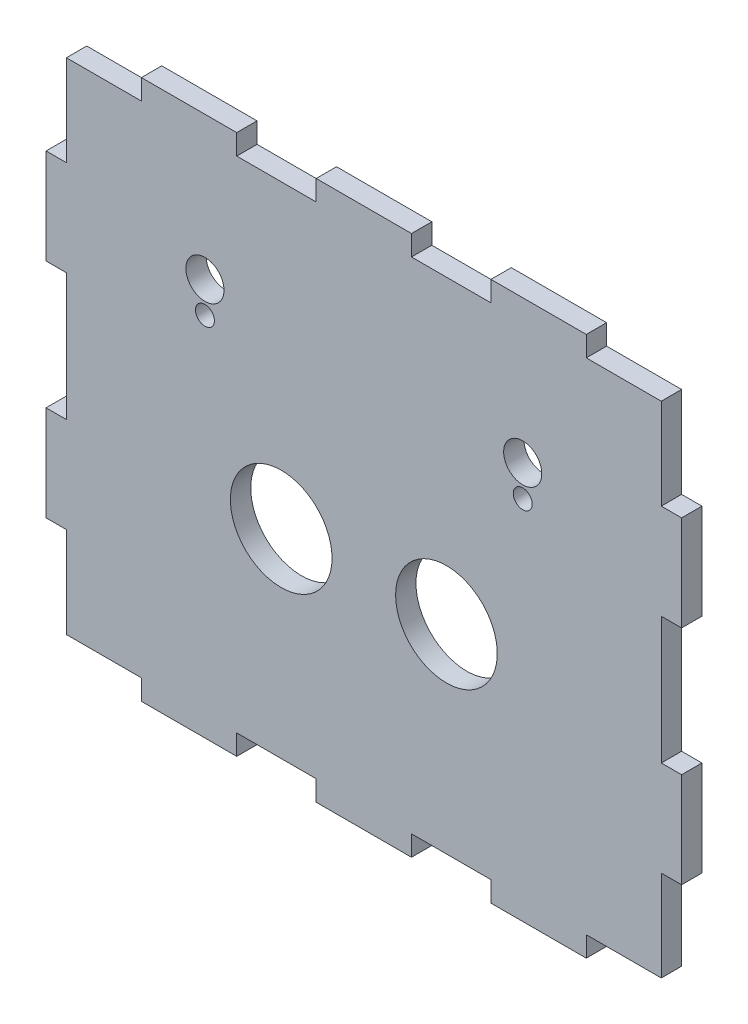
from build123d import *

# Parameters (mm, degrees)
SKETCH1_R           = 8
SKETCH1_R_2         = 3
SKETCH1_R_3         = 1.49
BOSS_EXTRUDE1_DEPTH = 3.2


with BuildPart() as part:
    # Sketch1 → Boss-Extrude1 (new body)
    with BuildSketch(Plane.XY):
        Polygon((-50, 10), (-50, 25), (-46.8, 25), (-46.8, 39.3), (-35, 39.3), (-35, 42.5), (-20, 42.5), (-20, 39.3), (-7.5, 39.3), (-7.5, 42.5), (7.5, 42.5), (7.5, 39.3), (20, 39.3), (20, 42.5), (35, 42.5), (35, 39.3), (46.8, 39.3), (46.8, 25), (50, 25), (50, 10), (46.8, 10), (46.8, -10), (50, -10), (50, -25), (46.8, -25), (46.8, -39.3), (35, -39.3), (35, -42.5), (20, -42.5), (20, -39.3), (7.5, -39.3), (7.5, -42.5), (-7.5, -42.5), (-7.5, -39.3), (-20, -39.3), (-20, -42.5), (-35, -42.5), (-35, -39.3), (-46.8, -39.3), (-46.8, -25), (-50, -25), (-50, -10), (-46.8, -10), (-46.8, 10), align=None)
        with Locations((-13, -8)):
            Circle(SKETCH1_R, mode=Mode.SUBTRACT)
        with Locations((-25, 20)):
            Circle(SKETCH1_R_2, mode=Mode.SUBTRACT)
        with Locations((-25, 15.1)):
            Circle(SKETCH1_R_3, mode=Mode.SUBTRACT)
        with Locations((13, -8)):
            Circle(SKETCH1_R, mode=Mode.SUBTRACT)
        with Locations((25, 15.1)):
            Circle(SKETCH1_R_3, mode=Mode.SUBTRACT)
        with Locations((25, 20)):
            Circle(SKETCH1_R_2, mode=Mode.SUBTRACT)
    extrude(amount=BOSS_EXTRUDE1_DEPTH)


solid = part.part
